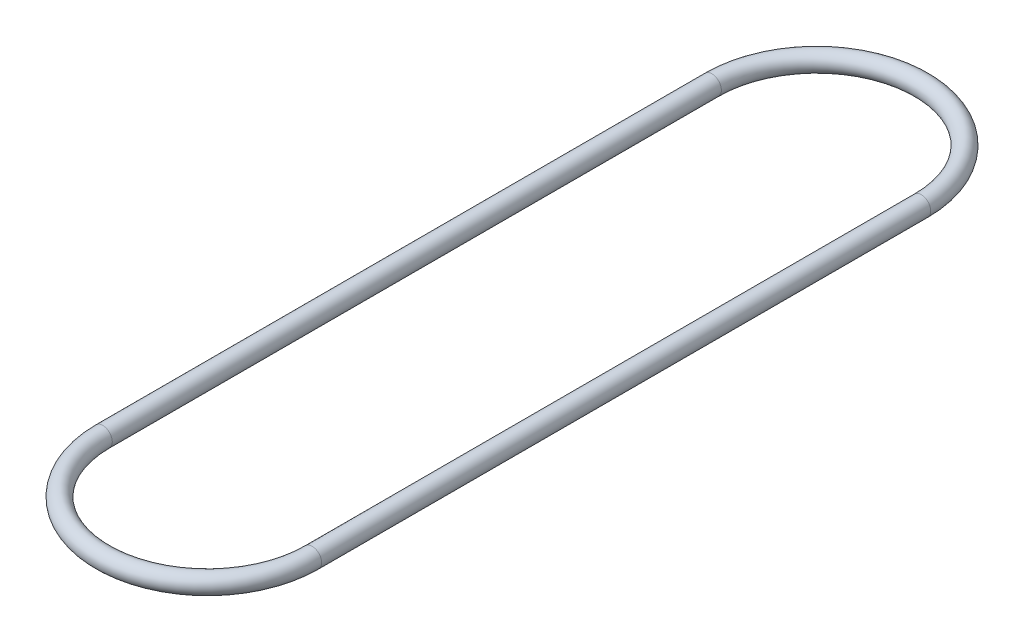
from build123d import *

# Parameters (mm, degrees)
SKETCH1_R = 3.175


with BuildPart() as part:
    # Sweep1: sweep along a path in Sketch2
    with BuildLine(Plane(origin=(0, 0, 0), x_dir=(1, 0, 0), z_dir=(0, 1, 0))) as sweep1_path:
        Line((0, 0), (0, 203.2))
        ThreePointArc((0, 203.2), (34.925, 238.125), (69.85, 203.2))
        Line((69.85, 203.2), (69.85, 0))
        ThreePointArc((69.85, 0), (34.925, -34.925), (0, 0))
    # Sketch1 → Sweep1 (sweep)
    with BuildSketch(Plane.XY):
        Circle(SKETCH1_R)
    sweep(path=sweep1_path.line)


solid = part.part
